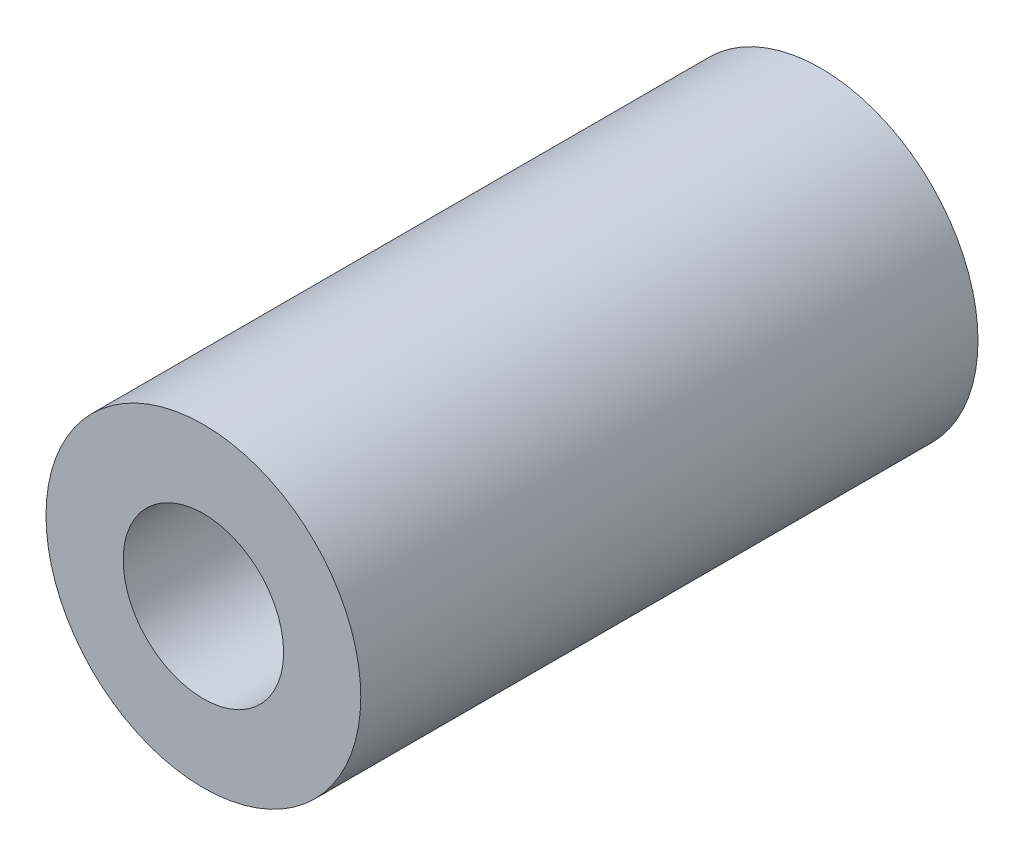
from build123d import *

# Parameters (mm, degrees)
CROQUIS1_R              = 5.1
CROQUIS1_R_2            = 2.6
SALIENTE_EXTRUIR1_DEPTH = 20


with BuildPart() as part:
    # Croquis1 → Saliente-Extruir1 (new body)
    with BuildSketch(Plane.XY):
        Circle(CROQUIS1_R)
        Circle(CROQUIS1_R_2, mode=Mode.SUBTRACT)
    extrude(amount=SALIENTE_EXTRUIR1_DEPTH)


solid = part.part
